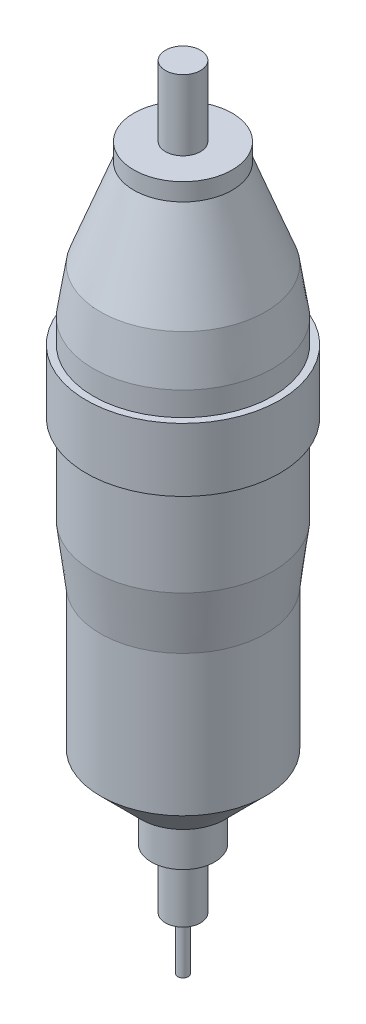
from build123d import *

# Parameters (mm, degrees)
SKETCH2_R      = 5
EXTRUDE1_DEPTH = 20
SKETCH3_R      = 1.5
EXTRUDE2_DEPTH = 15


with BuildPart() as part:
    # Sketch1 → Revolve1 (revolve)
    with BuildSketch(Plane.XY):
        Polygon((0, 86.10058483), (14, 86.10058483), (14, 81.10058483), (23.5, 55.889277686), (25.5, 42.889277686), (25.5, 36.10058483), (27.5, 36.10058483), (27.5, 18.10058483), (25.5, 18.10058483), (25.5, -7.110722314), (23.5, -23.39941517), (23.5, -63.39941517), (12, -74.89941517), (9, -74.89941517), (9, -86.89941517), (5, -86.89941517), (5, -103.89941517), (0, -103.89941517), align=None)
    revolve(axis=Axis((0, 86.10058483, 0), (0, -1, 0)))

    # Sketch2 → Extrude1 (add)
    with BuildSketch(Plane(origin=(0, 86.10058483, 0), x_dir=(1, 0, 0), z_dir=(0, 1, 0))):
        Circle(SKETCH2_R)
    extrude(amount=EXTRUDE1_DEPTH)

    # Sketch3 → Extrude2 (add)
    with BuildSketch(Plane.XZ.offset(103.89941517)):
        Circle(SKETCH3_R)
    extrude(amount=EXTRUDE2_DEPTH)


solid = part.part
